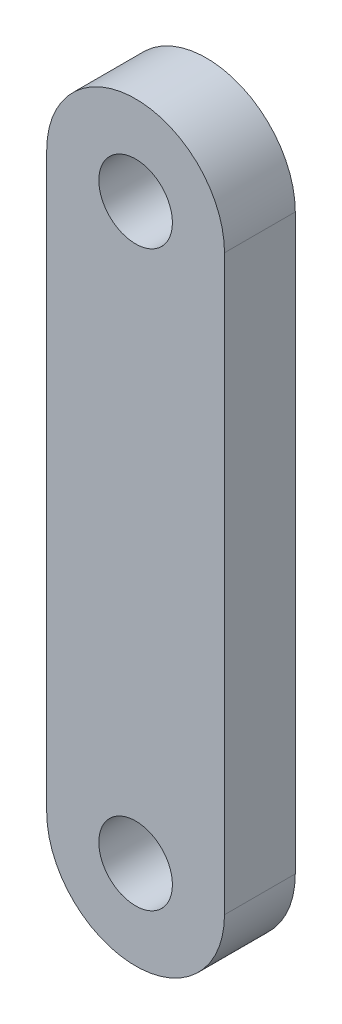
from build123d import *

# Parameters (mm, degrees)
SKETCH1_R           = 3.302
BOSS_EXTRUDE1_DEPTH = 6.35


with BuildPart() as part:
    # Sketch1 → Boss-Extrude1 (new body)
    with BuildSketch(Plane.XY):
        with BuildLine():
            Line((7.9756, 38.075002032), (7.9756, -13.359997968))
            ThreePointArc((7.9756, -13.359997968), (0, -21.335597968), (-7.9756, -13.359997968))
            Line((-7.9756, -13.359997968), (-7.9756, 38.075002032))
            ThreePointArc((-7.9756, 38.075002032), (0, 46.050602032), (7.9756, 38.075002032))
        make_face()
        with Locations((0, 38.075002032)):
            Circle(SKETCH1_R, mode=Mode.SUBTRACT)
        with Locations((0, -13.359997968)):
            Circle(SKETCH1_R, mode=Mode.SUBTRACT)
    extrude(amount=BOSS_EXTRUDE1_DEPTH)


solid = part.part
